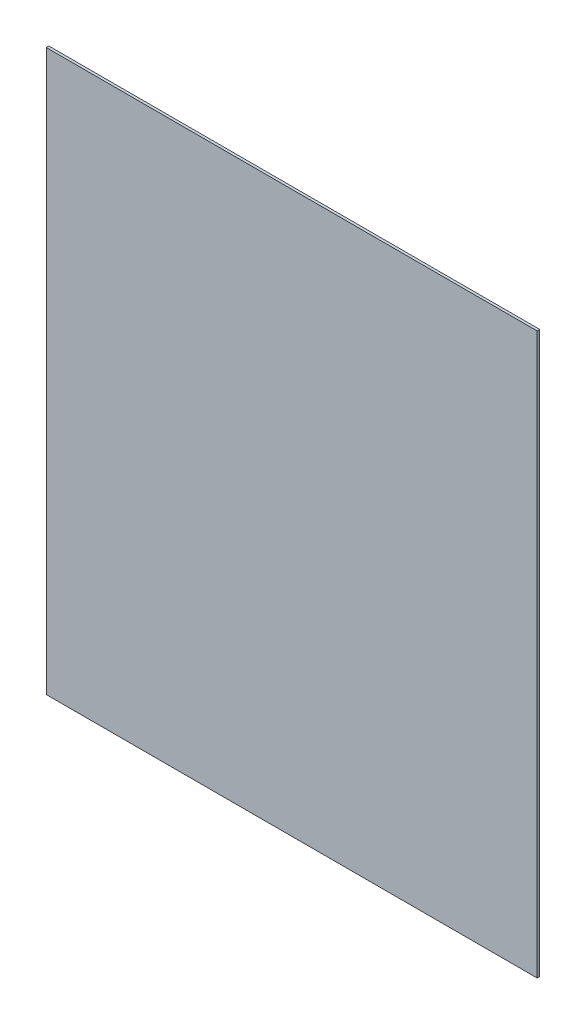
from build123d import *

# Parameters (mm, degrees)
SKICA1_W                = 565
SKICA1_H                = 645
P_IDAT_VYSUNUT_M1_DEPTH = 3


with BuildPart() as part:
    # Skica1 → Přidat vysunutím1 (new body)
    with BuildSketch(Plane.XY):
        Rectangle(SKICA1_W, SKICA1_H)
    extrude(amount=P_IDAT_VYSUNUT_M1_DEPTH)


solid = part.part
